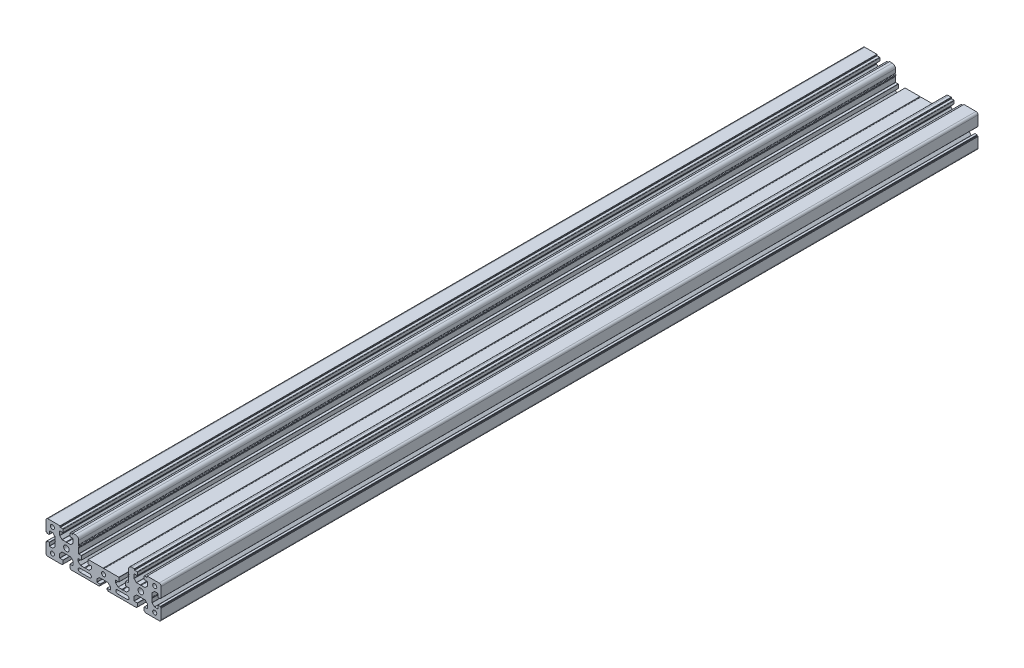
from build123d import *

# Parameters (mm, degrees)
SKETCH_1_R      = 2.5
SKETCH_1_R_2    = 3.4
EXTRUDE_1_DEPTH = 1000


with BuildPart() as part:
    # Эскиз1 → Бобышка-Вытянуть1 (new body)
    with BuildSketch(Plane.XY):
        with BuildLine():
            Line((-53.099999999, 18.700000011), (-53.099999999, 19.800000008))
            ThreePointArc((-53.099999999, 19.800000008), (-53.158578643, 19.941421364), (-53.299999999, 20.000000008))
            Line((-53.299999999, 20.000000008), (-67.999999998, 20.000000008))
            ThreePointArc((-67.999999998, 20.000000008), (-69.767766951, 19.267766961), (-70.499999998, 17.500000008))
            Line((-70.499999998, 17.500000008), (-70.499999998, 5.400000008))
            ThreePointArc((-70.499999998, 5.400000008), (-70.441421355, 5.258578652), (-70.3, 5.200000008))
            Line((-70.3, 5.200000008), (-69.700000002, 5.200000008))
            ThreePointArc((-69.700000002, 5.200000008), (-69.558578646, 5.141421364), (-69.500000002, 5.000000008))
            Line((-69.500000002, 5.000000008), (-69.500000002, 4.300000008))
            ThreePointArc((-69.500000002, 4.300000008), (-69.441421358, 4.158578651), (-69.300000002, 4.100000008))
            Line((-69.300000002, 4.100000008), (-66.700000002, 4.100000008))
            ThreePointArc((-66.700000002, 4.100000008), (-66.558578646, 4.158578651), (-66.500000002, 4.300000008))
            Line((-66.500000002, 4.300000008), (-66.500000002, 8.050000008))
            ThreePointArc((-66.500000002, 8.050000008), (-66.441421358, 8.191421364), (-66.300000002, 8.250000008))
            Line((-66.300000002, 8.250000008), (-62.382842714, 8.250000008))
            ThreePointArc((-62.382842714, 8.250000008), (-62.306306028, 8.234775914), (-62.241421358, 8.191421364))
            Line((-62.241421358, 8.191421364), (-59.358578646, 5.308578652))
            ThreePointArc((-59.358578646, 5.308578652), (-59.315224095, 5.243693982), (-59.300000002, 5.167157295))
            Line((-59.300000002, 5.167157295), (-59.300000002, 0.624499808))
            ThreePointArc((-59.300000002, 0.624499808), (-59.270416348, 0.494595997), (-59.187500002, 0.390312383))
            ThreePointArc((-59.187500002, 0.390312383), (-59.000000002, 8e-09), (-59.187500002, -0.390312367))
            ThreePointArc((-59.187500002, -0.390312367), (-59.270416348, -0.494595982), (-59.300000002, -0.624499792))
            Line((-59.300000002, -0.624499792), (-59.300000002, -5.16715728))
            ThreePointArc((-59.300000002, -5.16715728), (-59.315224095, -5.243693966), (-59.358578646, -5.308578636))
            Line((-59.358578646, -5.308578636), (-62.241421358, -8.191421349))
            ThreePointArc((-62.241421358, -8.191421349), (-62.306306028, -8.234775899), (-62.382842714, -8.249999992))
            Line((-62.382842714, -8.249999992), (-66.300000002, -8.249999992))
            ThreePointArc((-66.300000002, -8.249999992), (-66.441421358, -8.191421349), (-66.500000002, -8.049999992))
            Line((-66.500000002, -8.049999992), (-66.500000002, -4.299999992))
            ThreePointArc((-66.500000002, -4.299999992), (-66.558578646, -4.158578636), (-66.700000002, -4.099999992))
            Line((-66.700000002, -4.099999992), (-69.300000002, -4.099999992))
            ThreePointArc((-69.300000002, -4.099999992), (-69.441421358, -4.158578636), (-69.500000002, -4.299999992))
            Line((-69.500000002, -4.299999992), (-69.500000002, -4.999999992))
            ThreePointArc((-69.500000002, -4.999999992), (-69.558578646, -5.141421349), (-69.700000002, -5.199999992))
            Line((-69.700000002, -5.199999992), (-70.300000002, -5.199999992))
            ThreePointArc((-70.300000002, -5.199999992), (-70.441421358, -5.258578636), (-70.500000002, -5.399999992))
            Line((-70.500000002, -5.399999992), (-70.500000002, -17.499999992))
            ThreePointArc((-70.500000002, -17.499999992), (-69.767766955, -19.267766945), (-68.000000002, -19.999999992))
            Line((-68.000000002, -19.999999992), (-50.800000002, -19.999999992))
            ThreePointArc((-50.800000002, -19.999999992), (-50.658578646, -19.941421349), (-50.600000002, -19.799999992))
            Line((-50.600000002, -19.799999992), (-50.600000002, -19.199999992))
            ThreePointArc((-50.600000002, -19.199999992), (-50.541421358, -19.058578636), (-50.400000002, -18.999999992))
            Line((-50.400000002, -18.999999992), (-49.800000002, -18.999999992))
            ThreePointArc((-49.800000002, -18.999999992), (-49.658578646, -18.941421349), (-49.600000002, -18.799999992))
            Line((-49.600000002, -18.799999992), (-49.600000002, -14.699999992))
            ThreePointArc((-49.600000002, -14.699999992), (-49.658578646, -14.558578636), (-49.800000002, -14.499999992))
            Line((-49.800000002, -14.499999992), (-53.550000002, -14.499999992))
            ThreePointArc((-53.550000002, -14.499999992), (-53.691421358, -14.441421349), (-53.750000002, -14.299999992))
            Line((-53.750000002, -14.299999992), (-53.750000002, -9.707106773))
            ThreePointArc((-53.750000002, -9.707106773), (-53.711939768, -9.515765057), (-53.603553393, -9.353553383))
            Line((-53.603553393, -9.353553383), (-50.896446611, -6.646446602))
            ThreePointArc((-50.896446611, -6.646446602), (-50.734234937, -6.538060226), (-50.542893221, -6.499999992))
            Line((-50.542893221, -6.499999992), (-46.124499802, -6.499999992))
            ThreePointArc((-46.124499802, -6.499999992), (-45.994595991, -6.470416338), (-45.890312377, -6.387499992))
            ThreePointArc((-45.890312377, -6.387499992), (-45.500000002, -6.199999992), (-45.109687627, -6.387499992))
            ThreePointArc((-45.109687627, -6.387499992), (-45.005404013, -6.470416338), (-44.875500202, -6.499999992))
            Line((-44.875500202, -6.499999992), (-40.457106783, -6.499999992))
            ThreePointArc((-40.457106783, -6.499999992), (-40.265765067, -6.538060226), (-40.103553393, -6.646446602))
            Line((-40.103553393, -6.646446602), (-37.396446611, -9.353553383))
            ThreePointArc((-37.396446611, -9.353553383), (-37.288060236, -9.515765057), (-37.250000002, -9.707106773))
            Line((-37.250000002, -9.707106773), (-37.250000002, -14.299999992))
            ThreePointArc((-37.250000002, -14.299999992), (-37.308578646, -14.441421349), (-37.450000002, -14.499999992))
            Line((-37.450000002, -14.499999992), (-41.200000002, -14.499999992))
            ThreePointArc((-41.200000002, -14.499999992), (-41.341421358, -14.558578636), (-41.400000002, -14.699999992))
            Line((-41.400000002, -14.699999992), (-41.400000002, -18.799999992))
            ThreePointArc((-41.400000002, -18.799999992), (-41.341421358, -18.941421349), (-41.200000002, -18.999999992))
            Line((-41.200000002, -18.999999992), (-40.600000002, -18.999999992))
            ThreePointArc((-40.600000002, -18.999999992), (-40.458578646, -19.058578636), (-40.400000002, -19.199999992))
            Line((-40.400000002, -19.199999992), (-40.400000002, -19.799999992))
            ThreePointArc((-40.400000002, -19.799999992), (-40.341421358, -19.941421349), (-40.200000002, -19.999999992))
            Line((-40.200000002, -19.999999992), (-23.624499802, -19.999999992))
            ThreePointArc((-23.624499802, -19.999999992), (-23.494595991, -19.970416338), (-23.390312377, -19.887499992))
            ThreePointArc((-23.390312377, -19.887499992), (-23.000000002, -19.699999992), (-22.609687627, -19.887499992))
            ThreePointArc((-22.609687627, -19.887499992), (-22.505404013, -19.970416338), (-22.375500202, -19.999999992))
            Line((-22.375500202, -19.999999992), (-5.400000002, -19.999999992))
            ThreePointArc((-5.400000002, -19.999999992), (-5.258578646, -19.941421349), (-5.200000002, -19.799999992))
            Line((-5.200000002, -19.799999992), (-5.200000002, -19.199999992))
            ThreePointArc((-5.200000002, -19.199999992), (-5.141421358, -19.058578636), (-5.000000002, -18.999999992))
            Line((-5.000000002, -18.999999992), (-4.300000002, -18.999999992))
            ThreePointArc((-4.300000002, -18.999999992), (-4.158578646, -18.941421349), (-4.100000002, -18.799999992))
            Line((-4.100000002, -18.799999992), (-4.100000002, -17.499999992))
            ThreePointArc((-4.100000002, -17.499999992), (-4.158578646, -17.358578636), (-4.300000002, -17.299999992))
            Line((-4.300000002, -17.299999992), (-8.050000002, -17.299999992))
            ThreePointArc((-8.050000002, -17.299999992), (-8.191421358, -17.241421349), (-8.250000002, -17.099999992))
            Line((-8.250000002, -17.099999992), (-8.250000002, -13.882842707))
            ThreePointArc((-8.250000002, -13.882842707), (-8.234775909, -13.80630602), (-8.191421358, -13.74142135))
            Line((-8.191421358, -13.74142135), (-5.308578644, -10.858578636))
            ThreePointArc((-5.308578644, -10.858578636), (-5.243693974, -10.815224086), (-5.167157288, -10.799999992))
            Line((-5.167157288, -10.799999992), (-0.6244998, -10.799999992))
            ThreePointArc((-0.6244998, -10.799999992), (-0.494595989, -10.770416338), (-0.390312375, -10.687499992))
            ThreePointArc((-0.390312375, -10.687499992), (0, -10.499999992), (0.390312375, -10.687499992))
            ThreePointArc((0.390312375, -10.687499992), (0.494595989, -10.770416338), (0.6244998, -10.799999992))
            Line((0.6244998, -10.799999992), (5.167157288, -10.799999992))
            ThreePointArc((5.167157288, -10.799999992), (5.243693974, -10.815224086), (5.308578644, -10.858578636))
            Line((5.308578644, -10.858578636), (8.191421358, -13.74142135))
            ThreePointArc((8.191421358, -13.74142135), (8.234775908, -13.80630602), (8.250000002, -13.882842707))
            Line((8.250000002, -13.882842707), (8.250000002, -17.099999992))
            ThreePointArc((8.250000002, -17.099999992), (8.191421358, -17.241421349), (8.050000002, -17.299999992))
            Line((8.050000002, -17.299999992), (4.300000002, -17.299999992))
            ThreePointArc((4.300000002, -17.299999992), (4.158578646, -17.358578636), (4.100000002, -17.499999992))
            Line((4.100000002, -17.499999992), (4.100000002, -18.799999992))
            ThreePointArc((4.100000002, -18.799999992), (4.158578646, -18.941421349), (4.300000002, -18.999999992))
            Line((4.300000002, -18.999999992), (5.000000002, -18.999999992))
            ThreePointArc((5.000000002, -18.999999992), (5.141421358, -19.058578636), (5.200000002, -19.199999992))
            Line((5.200000002, -19.199999992), (5.200000002, -19.799999992))
            ThreePointArc((5.200000002, -19.799999992), (5.258578646, -19.941421349), (5.400000002, -19.999999992))
            Line((5.400000002, -19.999999992), (22.375500198, -19.999999992))
            ThreePointArc((22.375500198, -19.999999992), (22.505404009, -19.970416338), (22.609687623, -19.887499992))
            ThreePointArc((22.609687623, -19.887499992), (22.999999998, -19.699999992), (23.390312373, -19.887499992))
            ThreePointArc((23.390312373, -19.887499992), (23.494595987, -19.970416338), (23.624499798, -19.999999992))
            Line((23.624499798, -19.999999992), (40.200000002, -19.999999992))
            ThreePointArc((40.200000002, -19.999999992), (40.341421358, -19.941421349), (40.400000002, -19.799999992))
            Line((40.400000002, -19.799999992), (40.400000002, -19.199999992))
            ThreePointArc((40.400000002, -19.199999992), (40.458578646, -19.058578636), (40.600000002, -18.999999992))
            Line((40.600000002, -18.999999992), (41.200000002, -18.999999992))
            ThreePointArc((41.200000002, -18.999999992), (41.341421358, -18.941421349), (41.400000002, -18.799999992))
            Line((41.400000002, -18.799999992), (41.400000002, -14.699999992))
            ThreePointArc((41.400000002, -14.699999992), (41.341421358, -14.558578636), (41.200000002, -14.499999992))
            Line((41.200000002, -14.499999992), (37.450000002, -14.499999992))
            ThreePointArc((37.450000002, -14.499999992), (37.308578646, -14.441421349), (37.250000002, -14.299999992))
            Line((37.250000002, -14.299999992), (37.250000002, -9.707106773))
            ThreePointArc((37.250000002, -9.707106773), (37.288060236, -9.515765057), (37.396446611, -9.353553383))
            Line((37.396446611, -9.353553383), (40.103553393, -6.646446602))
            ThreePointArc((40.103553393, -6.646446602), (40.265765067, -6.538060226), (40.457106783, -6.499999992))
            Line((40.457106783, -6.499999992), (44.875500202, -6.499999992))
            ThreePointArc((44.875500202, -6.499999992), (45.005404013, -6.470416338), (45.109687627, -6.387499992))
            ThreePointArc((45.109687627, -6.387499992), (45.500000002, -6.199999992), (45.890312377, -6.387499992))
            ThreePointArc((45.890312377, -6.387499992), (45.994595991, -6.470416338), (46.124499802, -6.499999992))
            Line((46.124499802, -6.499999992), (50.542893221, -6.499999992))
            ThreePointArc((50.542893221, -6.499999992), (50.734234937, -6.538060226), (50.896446611, -6.646446602))
            Line((50.896446611, -6.646446602), (53.603553393, -9.353553383))
            ThreePointArc((53.603553393, -9.353553383), (53.711939768, -9.515765057), (53.750000002, -9.707106773))
            Line((53.750000002, -9.707106773), (53.750000002, -14.299999992))
            ThreePointArc((53.750000002, -14.299999992), (53.691421358, -14.441421349), (53.550000002, -14.499999992))
            Line((53.550000002, -14.499999992), (49.800000002, -14.499999992))
            ThreePointArc((49.800000002, -14.499999992), (49.658578646, -14.558578636), (49.600000002, -14.699999992))
            Line((49.600000002, -14.699999992), (49.600000002, -18.799999992))
            ThreePointArc((49.600000002, -18.799999992), (49.658578646, -18.941421349), (49.800000002, -18.999999992))
            Line((49.800000002, -18.999999992), (50.400000002, -18.999999992))
            ThreePointArc((50.400000002, -18.999999992), (50.541421358, -19.058578636), (50.600000002, -19.199999992))
            Line((50.600000002, -19.199999992), (50.600000002, -19.799999992))
            ThreePointArc((50.600000002, -19.799999992), (50.658578646, -19.941421349), (50.800000002, -19.999999992))
            Line((50.800000002, -19.999999992), (68.000000002, -19.999999992))
            ThreePointArc((68.000000002, -19.999999992), (69.767766955, -19.267766945), (70.500000002, -17.499999992))
            Line((70.500000002, -17.499999992), (70.500000002, -5.399999992))
            ThreePointArc((70.500000002, -5.399999992), (70.441421358, -5.258578636), (70.300000002, -5.199999992))
            Line((70.300000002, -5.199999992), (69.700000002, -5.199999992))
            ThreePointArc((69.700000002, -5.199999992), (69.558578646, -5.141421349), (69.500000002, -4.999999992))
            Line((69.500000002, -4.999999992), (69.500000002, -4.299999992))
            ThreePointArc((69.500000002, -4.299999992), (69.441421358, -4.158578636), (69.300000002, -4.099999992))
            Line((69.300000002, -4.099999992), (66.700000002, -4.099999992))
            ThreePointArc((66.700000002, -4.099999992), (66.558578646, -4.158578636), (66.500000002, -4.299999992))
            Line((66.500000002, -4.299999992), (66.500000002, -8.049999992))
            ThreePointArc((66.500000002, -8.049999992), (66.441421358, -8.191421349), (66.300000002, -8.249999992))
            Line((66.300000002, -8.249999992), (62.382842714, -8.249999992))
            ThreePointArc((62.382842714, -8.249999992), (62.306306028, -8.234775899), (62.241421358, -8.191421349))
            Line((62.241421358, -8.191421349), (59.358578646, -5.308578636))
            ThreePointArc((59.358578646, -5.308578636), (59.315224095, -5.243693966), (59.300000002, -5.16715728))
            Line((59.300000002, -5.16715728), (59.300000002, -0.624499792))
            ThreePointArc((59.300000002, -0.624499792), (59.270416348, -0.494595982), (59.187500002, -0.390312367))
            ThreePointArc((59.187500002, -0.390312367), (59.000000002, 8e-09), (59.187500002, 0.390312383))
            ThreePointArc((59.187500002, 0.390312383), (59.270416348, 0.494595997), (59.300000002, 0.624499808))
            Line((59.300000002, 0.624499808), (59.300000002, 5.167157295))
            ThreePointArc((59.300000002, 5.167157295), (59.315224095, 5.243693982), (59.358578646, 5.308578652))
            Line((59.358578646, 5.308578652), (62.241421358, 8.191421364))
            ThreePointArc((62.241421358, 8.191421364), (62.306306028, 8.234775914), (62.382842714, 8.250000008))
            Line((62.382842714, 8.250000008), (66.300000002, 8.250000008))
            ThreePointArc((66.300000002, 8.250000008), (66.441421358, 8.191421364), (66.500000002, 8.050000008))
            Line((66.500000002, 8.050000008), (66.500000002, 4.300000008))
            ThreePointArc((66.500000002, 4.300000008), (66.558578646, 4.158578651), (66.700000002, 4.100000008))
            Line((66.700000002, 4.100000008), (69.300000002, 4.100000008))
            ThreePointArc((69.300000002, 4.100000008), (69.441421358, 4.158578651), (69.500000002, 4.300000008))
            Line((69.500000002, 4.300000008), (69.500000002, 5.000000008))
            ThreePointArc((69.500000002, 5.000000008), (69.558578646, 5.141421364), (69.700000002, 5.200000008))
            Line((69.700000002, 5.200000008), (70.3, 5.200000008))
            ThreePointArc((70.3, 5.200000008), (70.441421355, 5.258578652), (70.499999998, 5.400000008))
            Line((70.499999998, 5.400000008), (70.499999998, 17.500000008))
            ThreePointArc((70.499999998, 17.500000008), (69.767766951, 19.267766961), (67.999999998, 20.000000008))
            Line((67.999999998, 20.000000008), (53.299999999, 20.000000008))
            ThreePointArc((53.299999999, 20.000000008), (53.158578643, 19.941421364), (53.099999999, 19.800000008))
            Line((53.099999999, 19.800000008), (53.099999999, 18.700000011))
            ThreePointArc((53.099999999, 18.700000011), (53.041421355, 18.558578654), (52.899999999, 18.500000011))
            Line((52.899999999, 18.500000011), (50.099999999, 18.500000011))
            ThreePointArc((50.099999999, 18.500000011), (49.746446608, 18.353553401), (49.599999999, 18.000000011))
            Line((49.599999999, 18.000000011), (49.599999999, 14.700000011))
            ThreePointArc((49.599999999, 14.700000011), (49.658578643, 14.558578654), (49.799999999, 14.500000011))
            Line((49.799999999, 14.500000011), (53.549999999, 14.500000011))
            ThreePointArc((53.549999999, 14.500000011), (53.691421355, 14.441421367), (53.749999999, 14.300000011))
            Line((53.749999999, 14.300000011), (53.749999999, 9.707106792))
            ThreePointArc((53.749999999, 9.707106792), (53.711939765, 9.515765076), (53.60355339, 9.353553401))
            Line((53.60355339, 9.353553401), (50.896446608, 6.64644662))
            ThreePointArc((50.896446608, 6.64644662), (50.734234934, 6.538060244), (50.542893218, 6.500000011))
            Line((50.542893218, 6.500000011), (46.124499799, 6.500000011))
            ThreePointArc((46.124499799, 6.500000011), (45.994595988, 6.470416356), (45.890312374, 6.387500011))
            ThreePointArc((45.890312374, 6.387500011), (45.499999999, 6.200000011), (45.109687624, 6.387500011))
            ThreePointArc((45.109687624, 6.387500011), (45.00540401, 6.470416356), (44.875500199, 6.500000011))
            Line((44.875500199, 6.500000011), (40.45710678, 6.500000011))
            ThreePointArc((40.45710678, 6.500000011), (40.265765064, 6.538060244), (40.10355339, 6.64644662))
            Line((40.10355339, 6.64644662), (37.396446608, 9.353553401))
            ThreePointArc((37.396446608, 9.353553401), (37.288060233, 9.515765076), (37.249999999, 9.707106792))
            Line((37.249999999, 9.707106792), (37.249999999, 14.300000011))
            ThreePointArc((37.249999999, 14.300000011), (37.308578643, 14.441421367), (37.449999999, 14.500000011))
            Line((37.449999999, 14.500000011), (41.199999999, 14.500000011))
            ThreePointArc((41.199999999, 14.500000011), (41.341421355, 14.558578654), (41.399999999, 14.700000011))
            Line((41.399999999, 14.700000011), (41.399999999, 18.000000011))
            ThreePointArc((41.399999999, 18.000000011), (41.25355339, 18.353553401), (40.899999999, 18.500000011))
            Line((40.899999999, 18.500000011), (38.099999999, 18.500000011))
            ThreePointArc((38.099999999, 18.500000011), (37.958578643, 18.558578654), (37.899999999, 18.700000011))
            Line((37.899999999, 18.700000011), (37.899999999, 19.800000008))
            ThreePointArc((37.899999999, 19.800000008), (37.841421355, 19.941421364), (37.699999999, 20.000000008))
            Line((37.699999999, 20.000000008), (34.5, 20.000000008))
            ThreePointArc((34.5, 20.000000008), (31.671572875, 18.828427132), (30.5, 16.000000008))
            Line((30.5, 16.000000008), (30.5, 11.366025412))
            ThreePointArc((30.5, 11.366025412), (30.566987298, 11.116025412), (30.75, 10.93301271))
            ThreePointArc((30.75, 10.93301271), (30.982962913, 10.370590485), (30.5, 10.000000008))
            ThreePointArc((30.5, 10.000000008), (30, 9.500000008), (30.5, 9.000000008))
            ThreePointArc((30.5, 9.000000008), (30.982962913, 8.62940953), (30.75, 8.066987306))
            ThreePointArc((30.75, 8.066987306), (30.566987298, 7.883974604), (30.5, 7.633974604))
            Line((30.5, 7.633974604), (30.5, 1.700000008))
            ThreePointArc((30.5, 1.700000008), (30.441421356, 1.558578651), (30.3, 1.500000008))
            Line((30.3, 1.500000008), (27.3, 1.500000008))
            ThreePointArc((27.3, 1.500000008), (27.158578644, 1.441421364), (27.1, 1.300000008))
            Line((27.1, 1.300000008), (27.1, -3.299999992))
            ThreePointArc((27.1, -3.299999992), (27.158578644, -3.441421349), (27.3, -3.499999992))
            Line((27.3, -3.499999992), (31.05, -3.499999992))
            ThreePointArc((31.05, -3.499999992), (31.191421356, -3.558578636), (31.25, -3.699999992))
            Line((31.25, -3.699999992), (31.25, -6.41715728))
            ThreePointArc((31.25, -6.41715728), (31.234775906, -6.493693966), (31.191421356, -6.558578636))
            Line((31.191421356, -6.558578636), (28.308578644, -9.441421349))
            ThreePointArc((28.308578644, -9.441421349), (28.243693974, -9.484775899), (28.167157288, -9.499999992))
            Line((28.167157288, -9.499999992), (23.6244998, -9.499999992))
            ThreePointArc((23.6244998, -9.499999992), (23.494595989, -9.529583647), (23.390312375, -9.612499992))
            ThreePointArc((23.390312375, -9.612499992), (23, -9.799999992), (22.609687625, -9.612499992))
            ThreePointArc((22.609687625, -9.612499992), (22.505404011, -9.529583647), (22.3755002, -9.499999992))
            Line((22.3755002, -9.499999992), (17.832842712, -9.499999992))
            ThreePointArc((17.832842712, -9.499999992), (17.756306026, -9.484775899), (17.691421356, -9.441421349))
            Line((17.691421356, -9.441421349), (14.808578644, -6.558578636))
            ThreePointArc((14.808578644, -6.558578636), (14.765224093, -6.493693966), (14.75, -6.41715728))
            Line((14.75, -6.41715728), (14.75, -3.699999992))
            ThreePointArc((14.75, -3.699999992), (14.808578644, -3.558578636), (14.95, -3.499999992))
            Line((14.95, -3.499999992), (18.7, -3.499999992))
            ThreePointArc((18.7, -3.499999992), (18.841421356, -3.441421349), (18.9, -3.299999992))
            Line((18.9, -3.299999992), (18.9, 1.300000008))
            ThreePointArc((18.9, 1.300000008), (18.841421356, 1.441421364), (18.7, 1.500000008))
            Line((18.7, 1.500000008), (0.6244998, 1.500000008))
            ThreePointArc((0.6244998, 1.500000008), (0.494595989, 1.470416353), (0.390312375, 1.387500008))
            ThreePointArc((0.390312375, 1.387500008), (0, 1.200000008), (-0.390312375, 1.387500008))
            ThreePointArc((-0.390312375, 1.387500008), (-0.494595989, 1.470416353), (-0.6244998, 1.500000008))
            Line((-0.6244998, 1.500000008), (-18.7, 1.500000008))
            ThreePointArc((-18.7, 1.500000008), (-18.841421356, 1.441421364), (-18.9, 1.300000008))
            Line((-18.9, 1.300000008), (-18.9, -3.299999992))
            ThreePointArc((-18.9, -3.299999992), (-18.841421356, -3.441421349), (-18.7, -3.499999992))
            Line((-18.7, -3.499999992), (-14.95, -3.499999992))
            ThreePointArc((-14.95, -3.499999992), (-14.808578644, -3.558578636), (-14.75, -3.699999992))
            Line((-14.75, -3.699999992), (-14.75, -6.41715728))
            ThreePointArc((-14.75, -6.41715728), (-14.765224093, -6.493693966), (-14.808578644, -6.558578636))
            Line((-14.808578644, -6.558578636), (-17.691421356, -9.441421349))
            ThreePointArc((-17.691421356, -9.441421349), (-17.756306026, -9.484775899), (-17.832842712, -9.499999992))
            Line((-17.832842712, -9.499999992), (-22.3755002, -9.499999992))
            ThreePointArc((-22.3755002, -9.499999992), (-22.505404011, -9.529583647), (-22.609687625, -9.612499992))
            ThreePointArc((-22.609687625, -9.612499992), (-23, -9.799999992), (-23.390312375, -9.612499992))
            ThreePointArc((-23.390312375, -9.612499992), (-23.494595989, -9.529583647), (-23.6244998, -9.499999992))
            Line((-23.6244998, -9.499999992), (-28.167157288, -9.499999992))
            ThreePointArc((-28.167157288, -9.499999992), (-28.243693974, -9.484775899), (-28.308578644, -9.441421349))
            Line((-28.308578644, -9.441421349), (-31.191421356, -6.558578636))
            ThreePointArc((-31.191421356, -6.558578636), (-31.234775906, -6.493693966), (-31.25, -6.41715728))
            Line((-31.25, -6.41715728), (-31.25, -3.699999992))
            ThreePointArc((-31.25, -3.699999992), (-31.191421356, -3.558578636), (-31.05, -3.499999992))
            Line((-31.05, -3.499999992), (-27.3, -3.499999992))
            ThreePointArc((-27.3, -3.499999992), (-27.158578644, -3.441421349), (-27.1, -3.299999992))
            Line((-27.1, -3.299999992), (-27.1, 1.300000008))
            ThreePointArc((-27.1, 1.300000008), (-27.158578644, 1.441421364), (-27.3, 1.500000008))
            Line((-27.3, 1.500000008), (-30.3, 1.500000008))
            ThreePointArc((-30.3, 1.500000008), (-30.441421356, 1.558578651), (-30.5, 1.700000008))
            Line((-30.5, 1.700000008), (-30.5, 7.633974604))
            ThreePointArc((-30.5, 7.633974604), (-30.566987298, 7.883974604), (-30.75, 8.066987306))
            ThreePointArc((-30.75, 8.066987306), (-30.982962913, 8.62940953), (-30.5, 9.000000008))
            ThreePointArc((-30.5, 9.000000008), (-30, 9.500000008), (-30.5, 10.000000008))
            ThreePointArc((-30.5, 10.000000008), (-30.982962913, 10.370590485), (-30.75, 10.93301271))
            ThreePointArc((-30.75, 10.93301271), (-30.566987298, 11.116025412), (-30.5, 11.366025412))
            Line((-30.5, 11.366025412), (-30.5, 16.000000008))
            ThreePointArc((-30.5, 16.000000008), (-31.671572875, 18.828427132), (-34.5, 20.000000008))
            Line((-34.5, 20.000000008), (-37.699999999, 20.000000008))
            ThreePointArc((-37.699999999, 20.000000008), (-37.841421355, 19.941421364), (-37.899999999, 19.800000008))
            Line((-37.899999999, 19.800000008), (-37.899999999, 18.700000011))
            ThreePointArc((-37.899999999, 18.700000011), (-37.958578643, 18.558578654), (-38.099999999, 18.500000011))
            Line((-38.099999999, 18.500000011), (-40.899999999, 18.500000011))
            ThreePointArc((-40.899999999, 18.500000011), (-41.25355339, 18.353553401), (-41.399999999, 18.000000011))
            Line((-41.399999999, 18.000000011), (-41.399999999, 14.700000011))
            ThreePointArc((-41.399999999, 14.700000011), (-41.341421355, 14.558578654), (-41.199999999, 14.500000011))
            Line((-41.199999999, 14.500000011), (-37.449999999, 14.500000011))
            ThreePointArc((-37.449999999, 14.500000011), (-37.308578643, 14.441421367), (-37.249999999, 14.300000011))
            Line((-37.249999999, 14.300000011), (-37.249999999, 9.707106792))
            ThreePointArc((-37.249999999, 9.707106792), (-37.288060233, 9.515765076), (-37.396446608, 9.353553401))
            Line((-37.396446608, 9.353553401), (-40.10355339, 6.64644662))
            ThreePointArc((-40.10355339, 6.64644662), (-40.265765064, 6.538060244), (-40.45710678, 6.500000011))
            Line((-40.45710678, 6.500000011), (-44.875500199, 6.500000011))
            ThreePointArc((-44.875500199, 6.500000011), (-45.00540401, 6.470416356), (-45.109687624, 6.387500011))
            ThreePointArc((-45.109687624, 6.387500011), (-45.499999999, 6.200000011), (-45.890312374, 6.387500011))
            ThreePointArc((-45.890312374, 6.387500011), (-45.994595988, 6.470416356), (-46.124499799, 6.500000011))
            Line((-46.124499799, 6.500000011), (-50.542893218, 6.500000011))
            ThreePointArc((-50.542893218, 6.500000011), (-50.734234934, 6.538060244), (-50.896446608, 6.64644662))
            Line((-50.896446608, 6.64644662), (-53.60355339, 9.353553401))
            ThreePointArc((-53.60355339, 9.353553401), (-53.711939765, 9.515765076), (-53.749999999, 9.707106792))
            Line((-53.749999999, 9.707106792), (-53.749999999, 14.300000011))
            ThreePointArc((-53.749999999, 14.300000011), (-53.691421355, 14.441421367), (-53.549999999, 14.500000011))
            Line((-53.549999999, 14.500000011), (-49.799999999, 14.500000011))
            ThreePointArc((-49.799999999, 14.500000011), (-49.658578643, 14.558578654), (-49.599999999, 14.700000011))
            Line((-49.599999999, 14.700000011), (-49.599999999, 18.000000011))
            ThreePointArc((-49.599999999, 18.000000011), (-49.746446608, 18.353553401), (-50.099999999, 18.500000011))
            Line((-50.099999999, 18.500000011), (-52.899999999, 18.500000011))
            ThreePointArc((-52.899999999, 18.500000011), (-53.041421355, 18.558578654), (-53.099999999, 18.700000011))
        make_face()
        with Locations((62.625000002, 14.125000008)):
            Circle(SKETCH_1_R, mode=Mode.SUBTRACT)
        with Locations((2e-09, -4.649999992)):
            Circle(SKETCH_1_R, mode=Mode.SUBTRACT)
        with Locations((-62.625000002, 14.125000008)):
            Circle(SKETCH_1_R, mode=Mode.SUBTRACT)
        with Locations((-45.500000002, 8e-09)):
            Circle(SKETCH_1_R_2, mode=Mode.SUBTRACT)
        with Locations((-62.625000002, -14.124999992)):
            Circle(SKETCH_1_R, mode=Mode.SUBTRACT)
        with Locations((45.500000002, 8e-09)):
            Circle(SKETCH_1_R_2, mode=Mode.SUBTRACT)
        with Locations((62.625000002, -14.124999992)):
            Circle(SKETCH_1_R, mode=Mode.SUBTRACT)
        with BuildLine():
            Line((29.000000002, -16.949999992), (17.000000002, -16.949999992))
            ThreePointArc((17.000000002, -16.949999992), (14.900000002, -14.849999992), (17.000000002, -12.749999992))
            Line((17.000000002, -12.749999992), (29.000000002, -12.749999992))
            ThreePointArc((29.000000002, -12.749999992), (31.100000002, -14.849999992), (29.000000002, -16.949999992))
        make_face(mode=Mode.SUBTRACT)
        with BuildLine():
            Line((-29.000000002, -12.749999992), (-17.000000002, -12.749999992))
            ThreePointArc((-17.000000002, -12.749999992), (-14.900000002, -14.849999992), (-17.000000002, -16.949999992))
            Line((-17.000000002, -16.949999992), (-29.000000002, -16.949999992))
            ThreePointArc((-29.000000002, -16.949999992), (-31.100000002, -14.849999992), (-29.000000002, -12.749999992))
        make_face(mode=Mode.SUBTRACT)
    extrude(amount=-EXTRUDE_1_DEPTH)


solid = part.part
